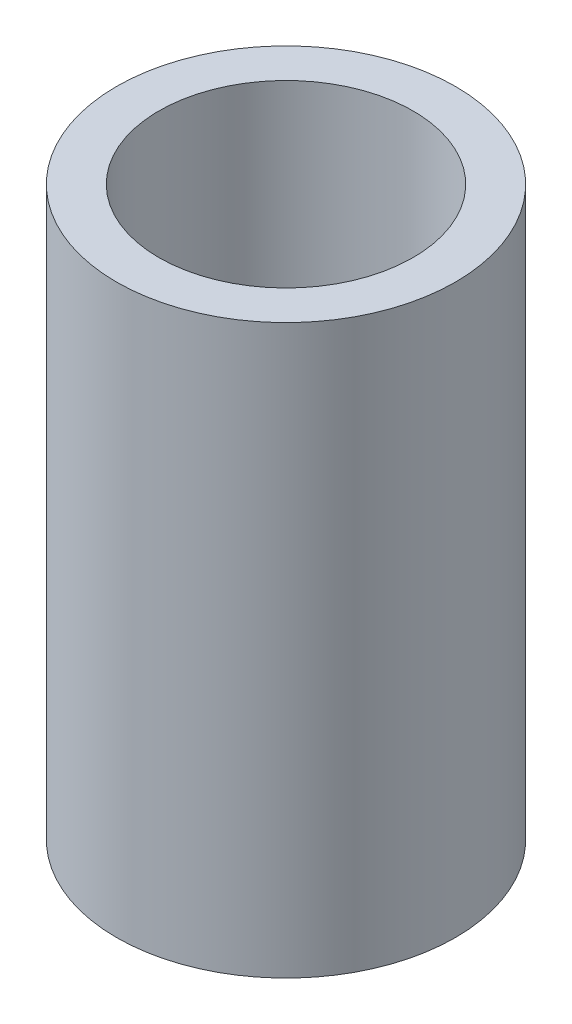
from build123d import *

# Parameters (mm, degrees)
SKETCH1_R           = 2
SKETCH1_R_2         = 1.5
BOSS_EXTRUDE1_DEPTH = 6.7


with BuildPart() as part:
    # Sketch1 → Boss-Extrude1 (new body)
    with BuildSketch(Plane(origin=(0, 0, 0), x_dir=(1, 0, 0), z_dir=(0, 1, 0))):
        Circle(SKETCH1_R)
        Circle(SKETCH1_R_2, mode=Mode.SUBTRACT)
    extrude(amount=BOSS_EXTRUDE1_DEPTH)


solid = part.part
